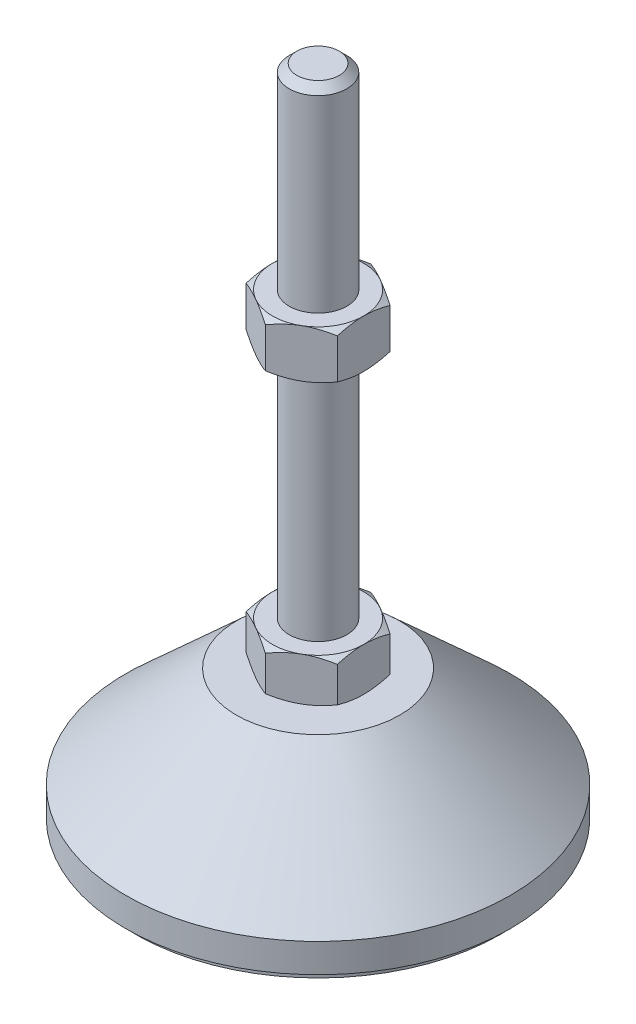
from build123d import *

# Parameters (mm, degrees)
EXTRUDE_1_DEPTH = 9
EXTRUDE_2_DEPTH = 10


with BuildPart() as part:
    # Эскиз1 → Повернуть1 (revolve)
    with BuildSketch(Plane.XY, mode=Mode.PRIVATE) as revolve_1_sk:
        Polygon((0, 0), (-38, 0), (-38, 2), (-40, 2), (-40, 8), (-17, 29), (-6, 29), (-6, 38), (-6, 136.4), (-4.4, 138), (0, 138), align=None)
    revolve(revolve_1_sk.sketch.rotate(Axis((0, 0, 0), (0, 1, 0)), 180), axis=Axis((0, 0, 0), (0, 1, 0)))  # turned: the seam where the file's is

    # Эскиз2 → Бобышка-Вытянуть1 (add)
    with BuildSketch(Plane(origin=(0, 29, 0), x_dir=(1, 0, 0), z_dir=(0, 1, 0))):
        Polygon((0, 10.969655115), (-9.5, 5.484827557), (-9.5, -5.484827557), (0, -10.969655115), (9.5, -5.484827557), (9.5, 5.484827557), align=None)
    extrude(amount=EXTRUDE_1_DEPTH)

    # Эскиз3 → Бобышка-Вытянуть2 (add)
    with BuildSketch(Plane(origin=(0, 87.2, 0), x_dir=(1, 0, 0), z_dir=(0, 1, 0))):
        Polygon((9.5, 5.484827557), (0, 10.969655115), (-9.5, 5.484827557), (-9.5, -5.484827557), (0, -10.969655115), (9.5, -5.484827557), align=None)
    extrude(amount=EXTRUDE_2_DEPTH)

    # Эскиз4 → Вырез-Повернуть2 (revolve, cut)
    with BuildSketch(Plane.XY, mode=Mode.PRIVATE) as cut_revolve_2_sk:
        Polygon((-18.160254038, 97.2), (-9.5, 97.2), (-18.160254038, 92.2), align=None)
        Polygon((-18.160254038, 87.2), (-18.160254038, 92.2), (-9.5, 87.2), align=None)
        Polygon((-17.294228634, 38), (-17.294228634, 33.5), (-9.5, 38), align=None)
        Polygon((-17.294228634, 33.5), (-17.294228634, 29), (-9.5, 29), align=None)
    revolve(cut_revolve_2_sk.sketch.rotate(Axis((0, 138, 0), (0, -1, 0)), 180), axis=Axis((0, 138, 0), (0, -1, 0)), mode=Mode.SUBTRACT)  # turned: the seam where the file's is


solid = part.part
